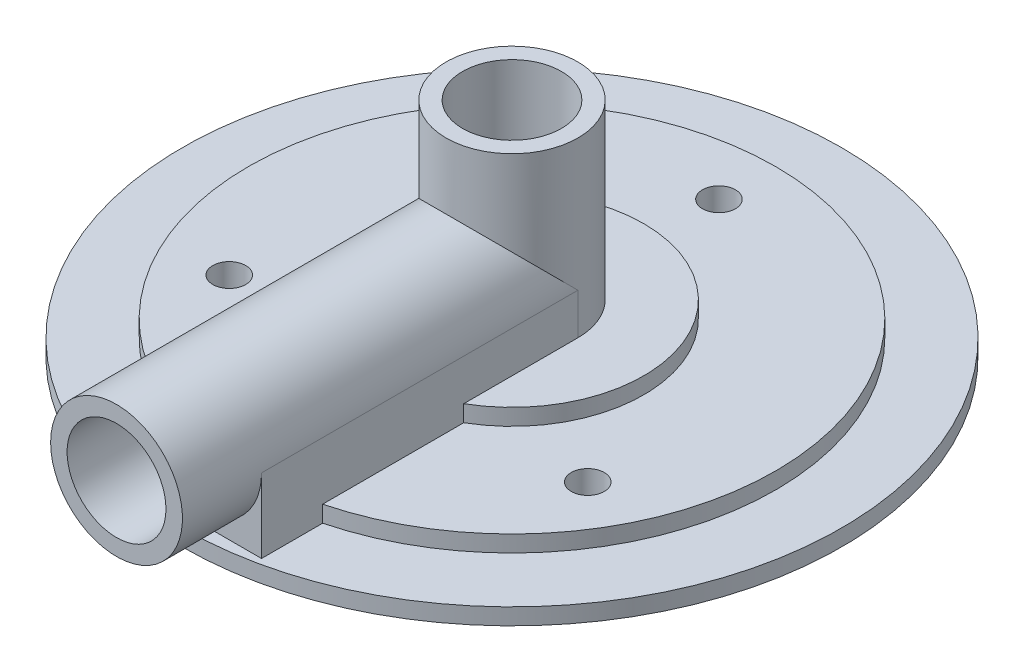
from build123d import *

# Parameters (mm, degrees)
SKETCH3_W           = 6.35
SKETCH3_H           = 38.1
EXTRUDE_THIN1_START = -30.48
EXTRUDE_THIN1_DEPTH = 30.48
HOLE1_D             = 9.525
HOLE1_DEPTH         = 38.1
HOLE2_D             = 9.525
HOLE3_D             = 3.175


with BuildPart() as part:
    # Sketch1 → Revolve1 (revolve)
    with BuildSketch(Plane.XY):
        Polygon((0, 20.6375), (6.35, 20.6375), (6.35, 3.96875), (12.7, 3.96875), (12.7, 2.38125), (25.4, 2.38125), (25.4, 0.79375), (31.75, 0.79375), (31.75, -0.79375), (25.4, -0.79375), (25.4, -2.38125), (12.7, -2.38125), (12.7, -3.96875), (6.35, -3.96875), (0, -3.96875), align=None)
    revolve(axis=Axis((0, 20.6375, 0), (0, -1, 0)))

    # Sketch3 → Revolve2 (revolve)
    with BuildSketch(Plane(origin=(0, 7.9375, 0), x_dir=(1, 0, 0), z_dir=(0, 1, 0))):
        with Locations((3.175, -19.05)):
            Rectangle(SKETCH3_W, SKETCH3_H)
    revolve(axis=Axis((0, 7.9375, 0), (0, 0, 1)))

    # Sketch4 → Extrude-Thin1 (add)
    with BuildSketch(Plane.XY.offset(30.48).offset(EXTRUDE_THIN1_START)):
        Polygon((6.35, 7.9375), (6.35, 0.79375), (-6.35, 0.79375), (-6.35, 7.9375), (-3.81, 7.9375), (-3.81, 3.33375), (3.81, 3.33375), (3.81, 7.9375), align=None)
    extrude(amount=EXTRUDE_THIN1_DEPTH)

    # Hole1
    with Locations(Plane.XY.offset(38.1)):
        with Locations((0, 7.9375)):
            Hole(HOLE1_D / 2, depth=HOLE1_DEPTH)

    # Hole2 (through all)
    with Locations(Plane(origin=(0, 20.6375, 0), x_dir=(1, 0, 0), z_dir=(0, 1, 0))):
        with Locations((0, 0)):
            Hole(HOLE2_D / 2)

    # Hole3 (through all)
    with Locations(Plane(origin=(0, 2.38125, 0), x_dir=(1, 0, 0), z_dir=(0, 1, 0))):
        with Locations((0, 19.939), (17.267680526, -9.9695), (-17.267680526, -9.9695)):
            Hole(HOLE3_D / 2)


solid = part.part
